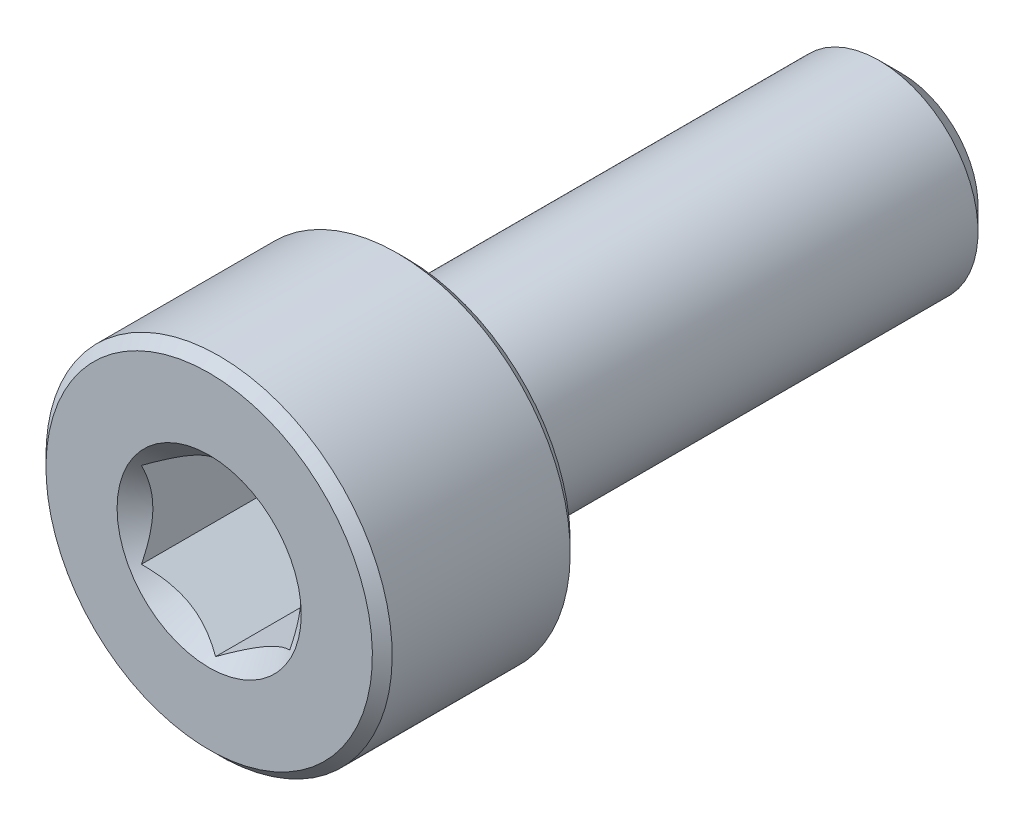
from build123d import *

# Parameters (mm, degrees)
CUT_EXTRUDE1_DEPTH = 3
SKETCH4_R          = 1.861954618
CUT_EXTRUDE2_DEPTH = 3
CUT_EXTRUDE2_DRAFT = -45


with BuildPart() as part:
    # Sketch2 → Revolve1 (revolve)
    with BuildSketch(Plane(origin=(0, 0, 0), x_dir=(0, 0, -1), z_dir=(1, 0, 0))):
        with BuildLine():
            Line((-7, 0), (-7, 3.3))
            Line((-7, 3.3), (-6.8, 3.5))
            Line((-6.8, 3.5), (-3.2, 3.5))
            Line((-3.2, 3.5), (-3, 3.3))
            Line((-3, 3.3), (-3, 2.2))
            ThreePointArc((-3, 2.2), (-2.941421356, 2.058578644), (-2.8, 2))
            Line((-2.8, 2), (6.545336663, 2))
            Line((6.545336663, 2), (7, 1.545336663))
            Line((7, 1.545336663), (7, 0))
            Line((7, 0), (-7, 0))
        make_face()
    revolve(axis=Axis((0, 0, -7), (0, 0, 1)))

    # Sketch3 → Cut-Extrude1 (cut)
    with BuildSketch(Plane.XY.offset(7)):
        Polygon((1.5, -0.866025404), (1.5, 0.866025404), (0, 1.732050808), (-1.5, 0.866025404), (-1.5, -0.866025404), (0, -1.732050808), align=None)
    extrude(amount=-CUT_EXTRUDE1_DEPTH, mode=Mode.SUBTRACT)


with BuildPart() as cut_extrude2_tool:
    # Sketch4 → Cut-Extrude2 (with draft: the straight prism first)
    with BuildSketch(Plane.XY.offset(7)):
        Circle(SKETCH4_R)
    extrude(amount=-CUT_EXTRUDE2_DEPTH)
    # Cut-Extrude2: the draft: its side faces are tilted about the plane it starts from
    cut_extrude2_sides = [cut_extrude2_tool.faces().sort_by_distance(p)[0] for p in [
        (-1.861954618, 0, 5.5),
    ]]
    draft(cut_extrude2_sides, Plane.XY.offset(7), CUT_EXTRUDE2_DRAFT)


with BuildPart() as part_1:
    add(part.part)

    # Cut-Extrude2: cut by cut_extrude2_tool
    add(cut_extrude2_tool.part, mode=Mode.SUBTRACT)


solid = part_1.part
